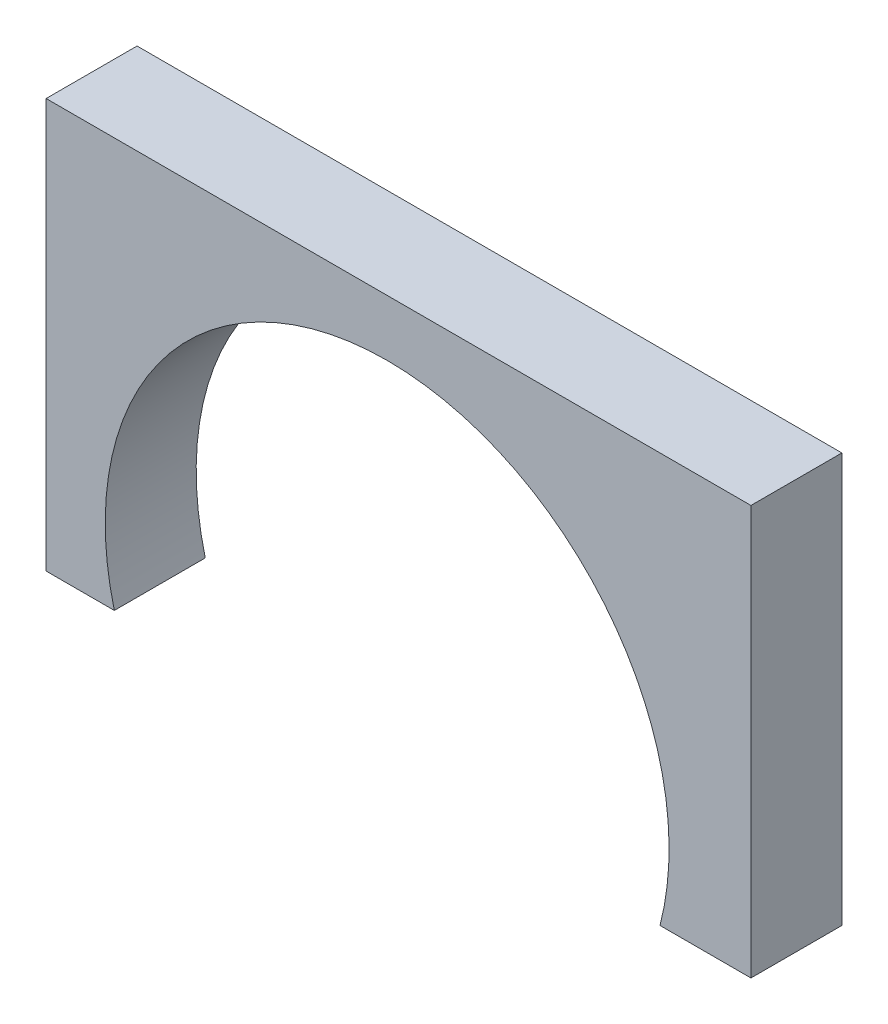
from build123d import *

# Parameters (mm, degrees)
BOSS_EXTRUDE1_DEPTH = 20


with BuildPart() as part:
    # Sketch1 → Boss-Extrude1 (new body)
    with BuildSketch(Plane.XY):
        with BuildLine():
            Line((-75, 74.379500648), (-75, -15.620499352))
            Line((-75, -15.620499352), (-60, -15.620499352))
            ThreePointArc((-60, -15.620499352), (0, 62), (60, -15.620499352))
            Line((60, -15.620499352), (80, -15.620499352))
            Line((80, -15.620499352), (80, 74.379500648))
            Line((80, 74.379500648), (-75, 74.379500648))
        make_face()
    extrude(amount=BOSS_EXTRUDE1_DEPTH)


solid = part.part
